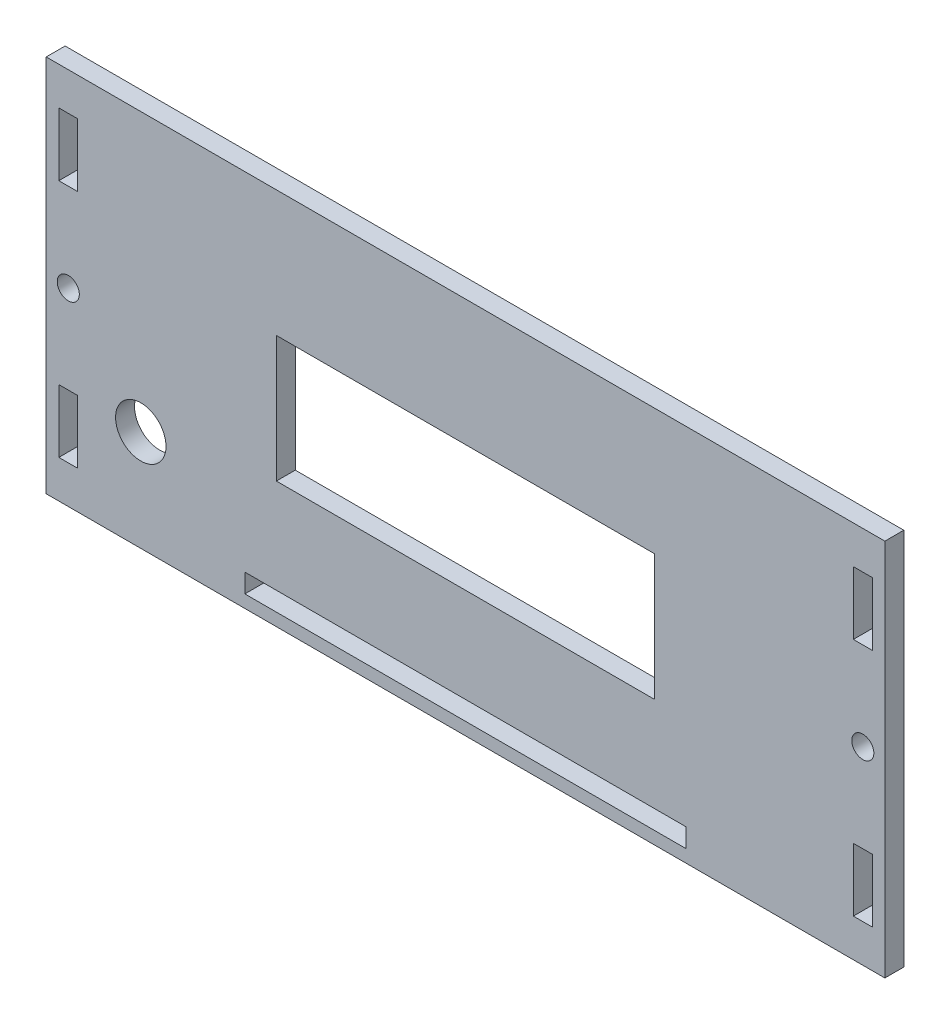
from build123d import *

# Parameters (mm, degrees)
SKETCH1_W           = 133
SKETCH1_H           = 60
SKETCH1_R           = 4
SKETCH1_R_2         = 1.75
SKETCH1_W_2         = 3
SKETCH1_H_2         = 10
SKETCH1_W_3         = 60
SKETCH1_H_3         = 20
SKETCH1_W_4         = 70
SKETCH1_H_4         = 3
BOSS_EXTRUDE2_DEPTH = 3


with BuildPart() as part:
    # Sketch1 → Boss-Extrude2 (new body)
    with BuildSketch(Plane.XY):
        Rectangle(SKETCH1_W, SKETCH1_H)
        with Locations((-51.5, -14)):
            Circle(SKETCH1_R, mode=Mode.SUBTRACT)
        with Locations((-63, 0)):
            Circle(SKETCH1_R_2, mode=Mode.SUBTRACT)
        with Locations((63, 0)):
            Circle(SKETCH1_R_2, mode=Mode.SUBTRACT)
        with Locations((63, 19)):
            Rectangle(SKETCH1_W_2, SKETCH1_H_2, mode=Mode.SUBTRACT)
        Rectangle(SKETCH1_W_3, SKETCH1_H_3, mode=Mode.SUBTRACT)
        with Locations((0, -26.5)):
            Rectangle(SKETCH1_W_4, SKETCH1_H_4, mode=Mode.SUBTRACT)
        with Locations((-63, 19)):
            Rectangle(SKETCH1_W_2, SKETCH1_H_2, mode=Mode.SUBTRACT)
        with Locations((-63, -19)):
            Rectangle(SKETCH1_W_2, SKETCH1_H_2, mode=Mode.SUBTRACT)
        with Locations((63, -19)):
            Rectangle(SKETCH1_W_2, SKETCH1_H_2, mode=Mode.SUBTRACT)
    extrude(amount=BOSS_EXTRUDE2_DEPTH)


solid = part.part
